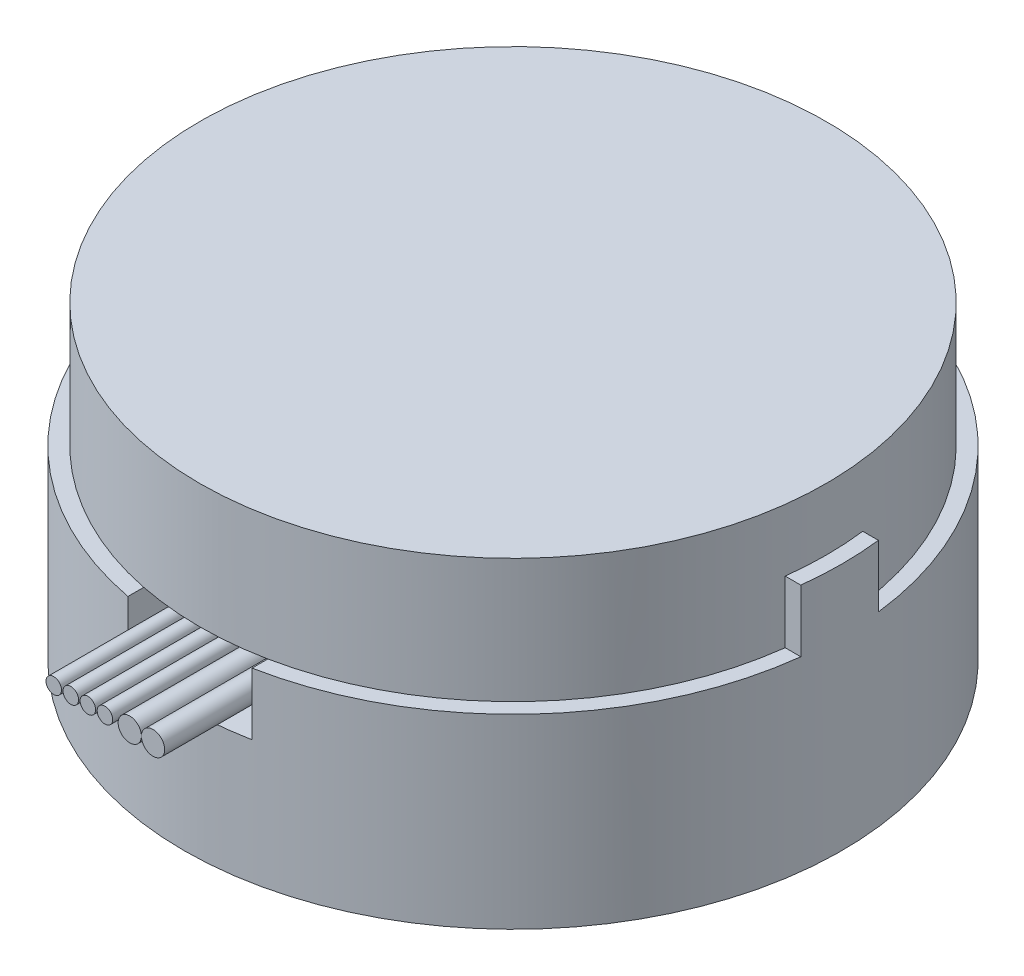
from build123d import *

# Parameters (mm, degrees)
SKETCH1_R             = 21.2
BOSS_EXTRUDE1_DEPTH   = 20
SKETCH2_OUTSIDE_W     = 57.042
SKETCH2_OUTSIDE_H     = 57.042
SKETCH2_OUTSIDE_R     = 20.2
CUT_EXTRUDE1_DEPTH    = 4
SKETCH3_OUTSIDE_W     = 57.042
SKETCH3_OUTSIDE_H     = 57.042
CUT_EXTRUDE2_DEPTH    = 4
SKETCH4_W             = 8
SKETCH4_H             = 4
CUT_EXTRUDE3_DEPTH    = 5
SKETCH5_R             = 0.75
BOSS_EXTRUDE3_DEPTH   = 10
BOSS_EXTRUDE3_2_DEPTH = 10
SKETCH5_R_2           = 0.5
BOSS_EXTRUDE3_3_DEPTH = 10
BOSS_EXTRUDE3_4_DEPTH = 10
BOSS_EXTRUDE3_5_DEPTH = 10
BOSS_EXTRUDE3_6_DEPTH = 10


with BuildPart() as part:
    # Sketch1 → Boss-Extrude1 (new body)
    with BuildSketch(Plane(origin=(0, 0, 0), x_dir=(1, 0, 0), z_dir=(0, 1, 0))):
        Circle(SKETCH1_R)
    extrude(amount=BOSS_EXTRUDE1_DEPTH)

    # Sketch2 outside → Cut-Extrude1 (cut)
    with BuildSketch(Plane(origin=(0, 20, 0), x_dir=(1, 0, 0), z_dir=(0, 1, 0))):
        Rectangle(SKETCH2_OUTSIDE_W, SKETCH2_OUTSIDE_H)
        Circle(SKETCH2_OUTSIDE_R, mode=Mode.SUBTRACT)
    extrude(amount=-CUT_EXTRUDE1_DEPTH, mode=Mode.SUBTRACT)

    # Sketch3 outside → Cut-Extrude2 (cut)
    with BuildSketch(Plane(origin=(0, 16, 0), x_dir=(1, 0, 0), z_dir=(0, 1, 0))):
        Rectangle(SKETCH3_OUTSIDE_W, SKETCH3_OUTSIDE_H)
        with BuildLine():
            Line((20.044700048, 2.5), (23.037339055, 2.5))
            Line((23.037339055, 2.5), (23.037339055, -2.5))
            Line((23.037339055, -2.5), (20.044700048, -2.5))
            ThreePointArc((20.044700048, -2.5), (0, -20.2), (-20.044700048, -2.5))
            Line((-20.044700048, -2.5), (-23.037339055, -2.5))
            Line((-23.037339055, -2.5), (-23.037339055, 2.5))
            Line((-23.037339055, 2.5), (-20.044700048, 2.5))
            ThreePointArc((-20.044700048, 2.5), (0, 20.2), (20.044700048, 2.5))
        make_face(mode=Mode.SUBTRACT)
    extrude(amount=-CUT_EXTRUDE2_DEPTH, mode=Mode.SUBTRACT)

    # Sketch4 → Cut-Extrude3 (cut)
    with BuildSketch(Plane.XY.offset(21.2)):
        with Locations((0, 10)):
            Rectangle(SKETCH4_W, SKETCH4_H)
    extrude(amount=-CUT_EXTRUDE3_DEPTH, mode=Mode.SUBTRACT)


with BuildPart() as body_2:
    # Sketch5 → Boss-Extrude3 (new body)
    with BuildSketch(Plane.XY.offset(16.2)):
        with Locations((3, 10.017134532)):
            Circle(SKETCH5_R)
    extrude(amount=BOSS_EXTRUDE3_DEPTH)


with BuildPart() as body_3:
    # Sketch5 → Boss-Extrude3 2 (new body)
    with BuildSketch(Plane.XY.offset(16.2)):
        with Locations((1.5, 10.017134532)):
            Circle(SKETCH5_R)
    extrude(amount=BOSS_EXTRUDE3_2_DEPTH)


with BuildPart() as body_4:
    # Sketch5 → Boss-Extrude3 3 (new body)
    with BuildSketch(Plane.XY.offset(16.2)):
        with Locations((-3.4, 10.017134532)):
            Circle(SKETCH5_R_2)
    extrude(amount=BOSS_EXTRUDE3_3_DEPTH)


with BuildPart() as body_5:
    # Sketch5 → Boss-Extrude3 4 (new body)
    with BuildSketch(Plane.XY.offset(16.2)):
        with Locations((-2.3, 10.017134532)):
            Circle(SKETCH5_R_2)
    extrude(amount=BOSS_EXTRUDE3_4_DEPTH)


with BuildPart() as body_6:
    # Sketch5 → Boss-Extrude3 5 (new body)
    with BuildSketch(Plane.XY.offset(16.2)):
        with Locations((-1.2, 10.017134532)):
            Circle(SKETCH5_R_2)
    extrude(amount=BOSS_EXTRUDE3_5_DEPTH)


with BuildPart() as body_7:
    # Sketch5 → Boss-Extrude3 6 (new body)
    with BuildSketch(Plane.XY.offset(16.2)):
        with Locations((-0.1, 10.017134532)):
            Circle(SKETCH5_R_2)
    extrude(amount=BOSS_EXTRUDE3_6_DEPTH)


solid = Compound([part.part, body_2.part, body_3.part, body_4.part, body_5.part, body_6.part, body_7.part])
